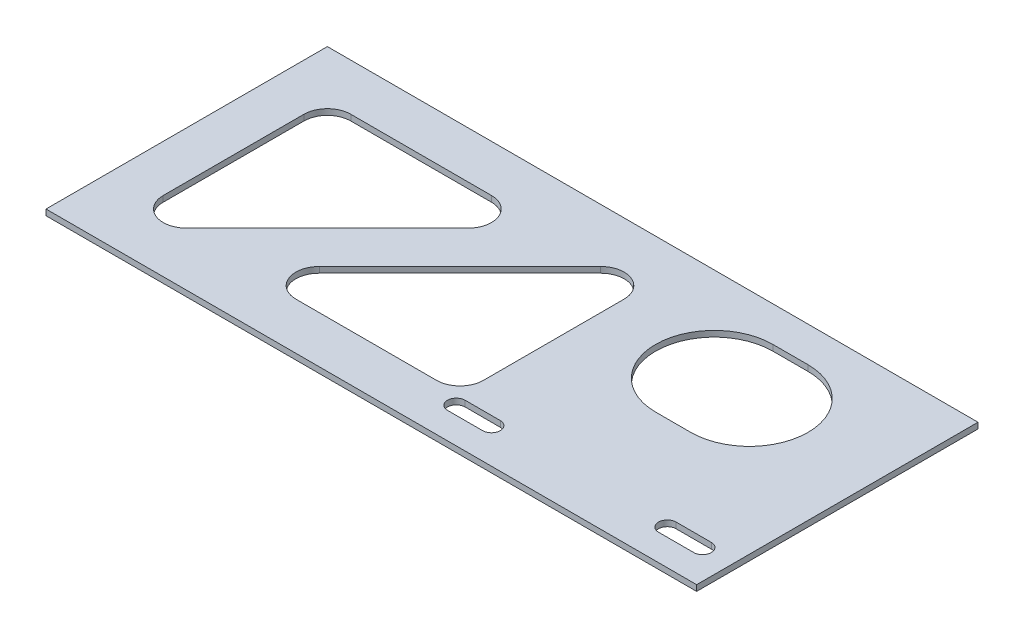
from build123d import *

# Parameters (mm, degrees)
SKETCH1_W           = 352.425
SKETCH1_H           = 152.4
BOSS_EXTRUDE1_DEPTH = 1.5875
CUT_EXTRUDE1_DEPTH  = 4.175
CUT_EXTRUDE2_DEPTH  = 4.175


with BuildPart() as part:
    # Sketch1 → Boss-Extrude1 (new body, symmetric)
    with BuildSketch(Plane(origin=(0, 0, 0), x_dir=(1, 0, 0), z_dir=(0, 1, 0))):
        Rectangle(SKETCH1_W, SKETCH1_H)
    extrude(amount=BOSS_EXTRUDE1_DEPTH, both=True)

    # Sketch2 → Cut-Extrude1 (cut, through all)
    with BuildSketch(Plane(origin=(0, 1.5875, 0), x_dir=(1, 0, 0), z_dir=(0, 1, 0))):
        with BuildLine():
            Line((103.1875, -6.35), (84.1375, -6.35))
            ThreePointArc((84.1375, -6.35), (52.3875, 25.4), (84.1375, 57.15))
            Line((84.1375, 57.15), (103.1875, 57.15))
            ThreePointArc((103.1875, 57.15), (134.9375, 25.4), (103.1875, -6.35))
        make_face()
        with BuildLine():
            Line((-138.1125, 50.8), (-61.9125, 50.8))
            ThreePointArc((-61.9125, 50.8), (-50.179229937, 42.960079591), (-52.932243879, 29.119743879))
            Line((-52.932243879, 29.119743879), (-129.132243879, -47.080256121))
            ThreePointArc((-129.132243879, -47.080256121), (-142.972579591, -49.833270063), (-150.8125, -38.1))
            Line((-150.8125, -38.1), (-150.8125, 38.1))
            ThreePointArc((-150.8125, 38.1), (-147.092756121, 47.080256121), (-138.1125, 50.8))
        make_face()
        with BuildLine():
            Line((-66.270451031, -50.8), (9.929548969, -50.8))
            ThreePointArc((9.929548969, -50.8), (18.90980509, -47.080256121), (22.629548969, -38.1))
            Line((22.629548969, -38.1), (22.629548969, 38.1))
            ThreePointArc((22.629548969, 38.1), (14.78962856, 49.833270063), (0.949292847, 47.080256121))
            Line((0.949292847, 47.080256121), (-75.250707153, -29.119743879))
            ThreePointArc((-75.250707153, -29.119743879), (-78.003721094, -42.960079591), (-66.270451031, -50.8))
        make_face()
    extrude(amount=-CUT_EXTRUDE1_DEPTH, mode=Mode.SUBTRACT)

    # Sketch3 → Cut-Extrude2 (cut, through all)
    with BuildSketch(Plane(origin=(0, 1.5875, 0), x_dir=(1, 0, 0), z_dir=(0, 1, 0))):
        with BuildLine():
            Line((160.3375, -61.9125), (141.2875, -61.9125))
            ThreePointArc((141.2875, -61.9125), (136.525, -57.15), (141.2875, -52.3875))
            Line((141.2875, -52.3875), (160.3375, -52.3875))
            ThreePointArc((160.3375, -52.3875), (165.1, -57.15), (160.3375, -61.9125))
        make_face()
        with BuildLine():
            Line((46.0375, -61.9125), (26.9875, -61.9125))
            ThreePointArc((26.9875, -61.9125), (22.225, -57.15), (26.9875, -52.3875))
            Line((26.9875, -52.3875), (46.0375, -52.3875))
            ThreePointArc((46.0375, -52.3875), (50.8, -57.15), (46.0375, -61.9125))
        make_face()
    extrude(amount=-CUT_EXTRUDE2_DEPTH, mode=Mode.SUBTRACT)


solid = part.part
